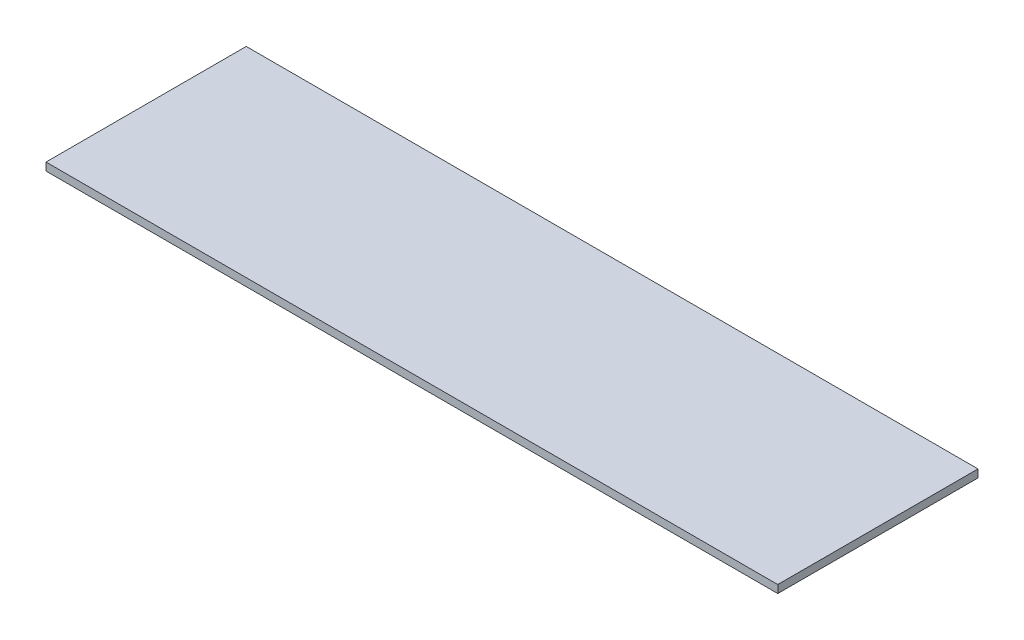
from build123d import *

# Parameters (mm, degrees)
SKETCH1_W           = 279.7556
SKETCH1_H           = 76.5556
BOSS_EXTRUDE1_DEPTH = 2.9972


with BuildPart() as part:
    # Sketch1 → Boss-Extrude1 (new body)
    with BuildSketch(Plane(origin=(0, 0, 0), x_dir=(1, 0, 0), z_dir=(0, 1, 0))):
        with Locations((139.8778, -38.2778)):
            Rectangle(SKETCH1_W, SKETCH1_H)
    extrude(amount=BOSS_EXTRUDE1_DEPTH)


solid = part.part
